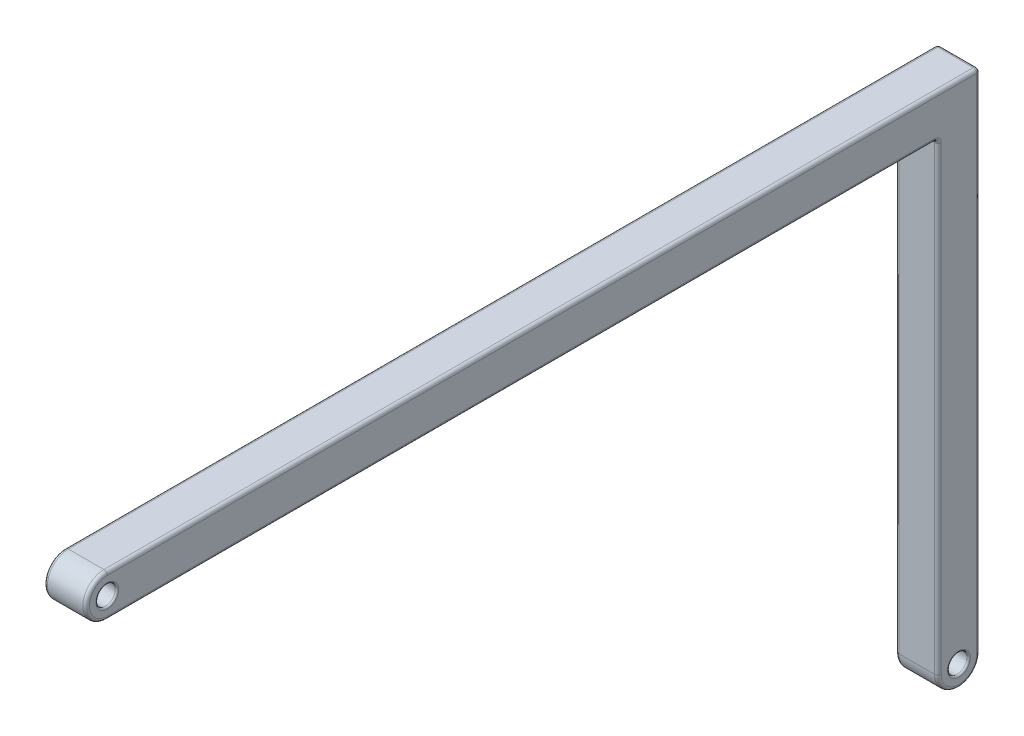
from build123d import *

# Parameters (mm, degrees)
SKETCH1_R           = 0.575
BOSS_EXTRUDE1_DEPTH = 2.5
FILLET2_R           = 0.1
FILLET3_R           = 0.2


with BuildPart() as part:
    # Sketch1 → Boss-Extrude1 (new body)
    with BuildSketch(Plane(origin=(0, 0, 0), x_dir=(0, 0, -1), z_dir=(1, 0, 0))):
        with BuildLine():
            Line((0, 0), (50.5, 0))
            Line((50.5, 0), (51.75, 0))
            Line((51.75, 0), (51.75, -30))
            ThreePointArc((51.75, -30), (50.5, -31.25), (49.25, -30))
            Line((49.25, -30), (49.25, -2.5))
            Line((49.25, -2.5), (0, -2.5))
            ThreePointArc((0, -2.5), (-1.25, -1.25), (0, 0))
        make_face()
        with Locations((0, -1.25)):
            Circle(SKETCH1_R, mode=Mode.SUBTRACT)
        with Locations((50.5, -30)):
            Circle(SKETCH1_R, mode=Mode.SUBTRACT)
    extrude(amount=BOSS_EXTRUDE1_DEPTH)

    # Fillet2
    fillet2_edges = [part.edges().sort_by_distance(p)[0] for p in [
        (0, -1.25, 0.575),
        (2.5, -1.25, 0.575),
        (0, -30, -49.925),
        (2.5, -30, -49.925),
    ]]
    fillet(fillet2_edges, radius=FILLET2_R)

    # Fillet3
    fillet3_edges = [part.edges().sort_by_distance(p)[0] for p in [
        (0, -1.25, 1.25),
        (1.25, 0, -51.75),
        (2.5, -16.25, -49.25),
        (1.25, -2.5, -49.25),
        (2.5, -31.25, -50.5),
        (2.5, -15, -51.75),
        (2.5, 0, -25.875),
        (2.5, -1.25, 1.25),
        (0, 0, -25.875),
        (0, -15, -51.75),
        (0, -31.25, -50.5),
        (2.5, -2.5, -24.625),
        (0, -16.25, -49.25),
        (0, -2.5, -24.625),
    ]]
    fillet(fillet3_edges, radius=FILLET3_R)


solid = part.part
